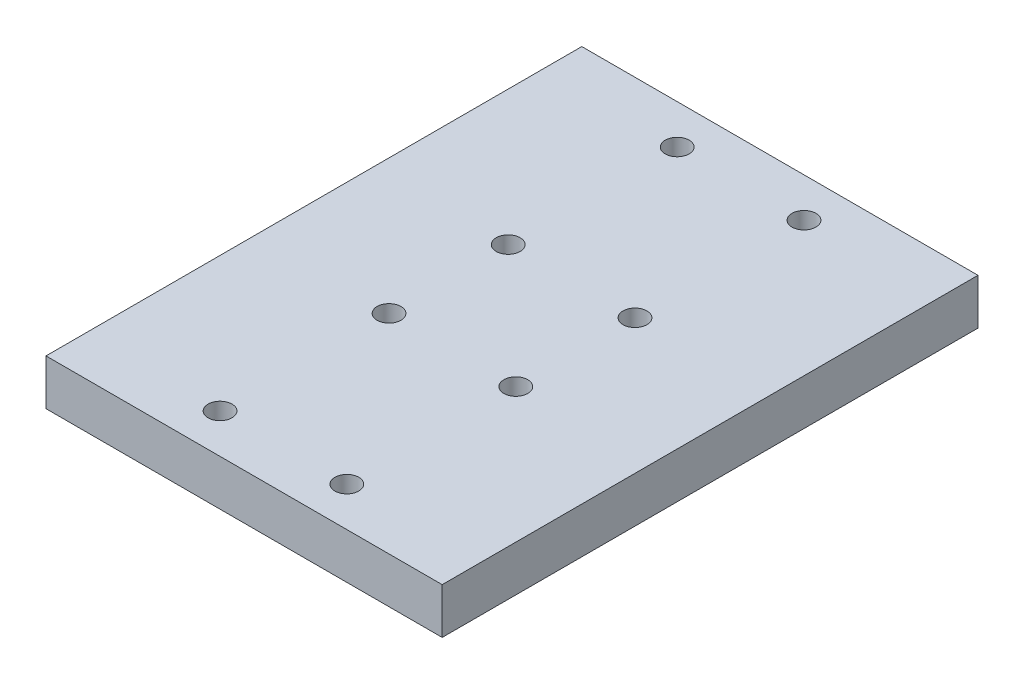
from build123d import *

# Parameters (mm, degrees)
SKETCH1_W           = 55
SKETCH1_H           = 74.38
SKETCH1_R           = 1.66
BOSS_EXTRUDE1_DEPTH = 6.35


with BuildPart() as part:
    # Sketch1 → Boss-Extrude1 (new body)
    with BuildSketch(Plane(origin=(0, 0, 0), x_dir=(1, 0, 0), z_dir=(0, 1, 0))):
        with Locations((27.5, 37.19)):
            Rectangle(SKETCH1_W, SKETCH1_H)
        with Locations((18.7, 68.92)):
            Circle(SKETCH1_R, mode=Mode.SUBTRACT)
        with Locations((36.3, 68.92)):
            Circle(SKETCH1_R, mode=Mode.SUBTRACT)
        with Locations((36.3, 45.46)):
            Circle(SKETCH1_R, mode=Mode.SUBTRACT)
        with Locations((18.7, 45.46)):
            Circle(SKETCH1_R, mode=Mode.SUBTRACT)
        with Locations((18.7, 28.92)):
            Circle(SKETCH1_R, mode=Mode.SUBTRACT)
        with Locations((36.3, 28.92)):
            Circle(SKETCH1_R, mode=Mode.SUBTRACT)
        with Locations((36.3, 5.46)):
            Circle(SKETCH1_R, mode=Mode.SUBTRACT)
        with Locations((18.7, 5.46)):
            Circle(SKETCH1_R, mode=Mode.SUBTRACT)
    extrude(amount=BOSS_EXTRUDE1_DEPTH)


solid = part.part
